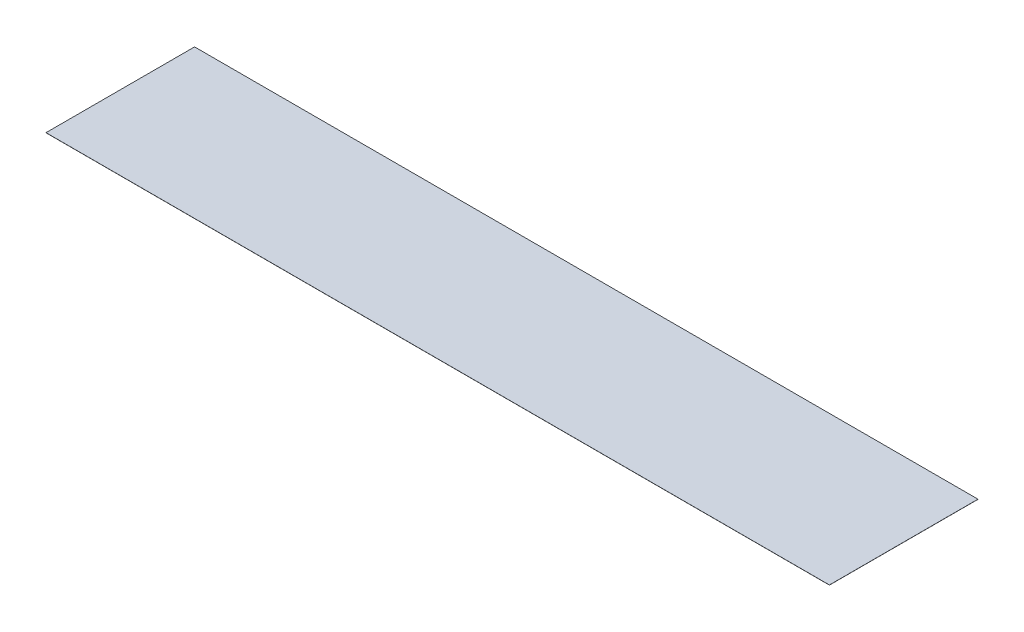
from build123d import *

# Parameters (mm, degrees)
SKETCH1_W           = 580
SKETCH1_H           = 110
BOSS_EXTRUDE1_DEPTH = 0.1


with BuildPart() as part:
    # Sketch1 → Boss-Extrude1 (new body)
    with BuildSketch(Plane(origin=(0, 0, 0), x_dir=(1, 0, 0), z_dir=(0, 1, 0))):
        with Locations((290, 55)):
            Rectangle(SKETCH1_W, SKETCH1_H)
    extrude(amount=BOSS_EXTRUDE1_DEPTH)


solid = part.part
